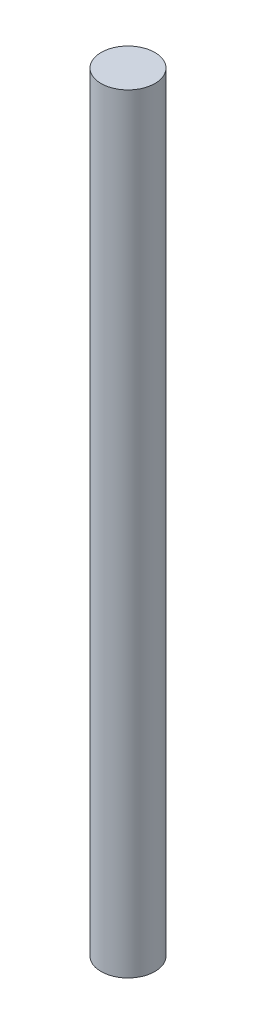
from build123d import *

# Parameters (mm, degrees)
SKETCH1_R           = 8
BOSS_EXTRUDE1_DEPTH = 228.6


with BuildPart() as part:
    # Sketch1 → Boss-Extrude1 (new body)
    with BuildSketch(Plane(origin=(0, 0, 0), x_dir=(1, 0, 0), z_dir=(0, 1, 0))):
        Circle(SKETCH1_R)
    extrude(amount=BOSS_EXTRUDE1_DEPTH)


solid = part.part
